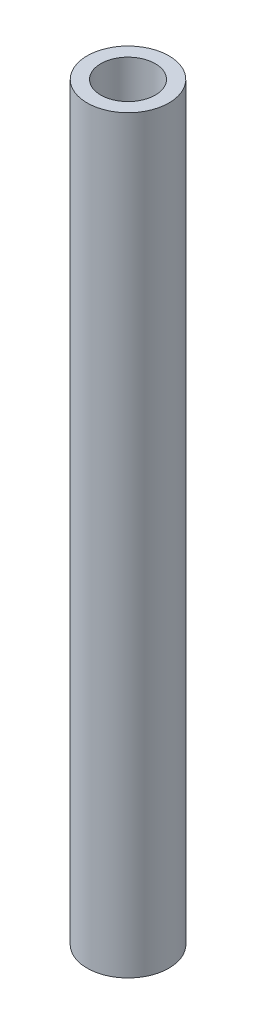
from build123d import *


with BuildPart() as part:
    # Croquis1 → Revolución1 (revolve)
    with BuildSketch(Plane.XY):
        Polygon((-3, -27.5), (-2, -27.5), (-2, 27.5), (-2.6, 27.5), (-3, 27.5), align=None)
    revolve(axis=Axis((0, -0.720216084, 0), (0, 1, 0)))


solid = part.part
